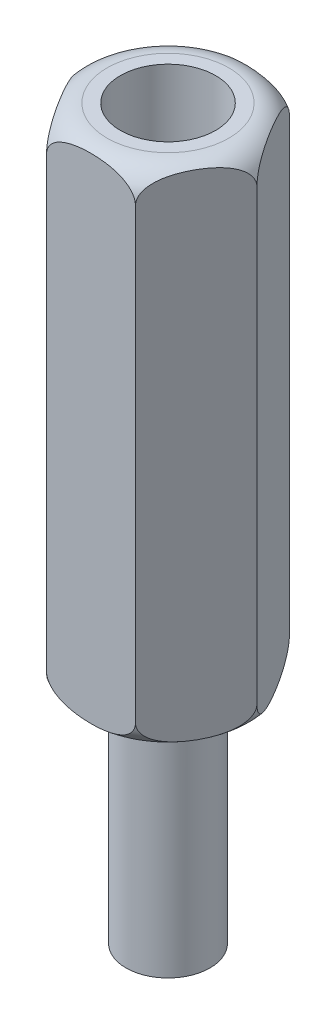
from build123d import *

# Parameters (mm, degrees)
BOSS_EXTRUDE1_DEPTH      = 18
M3_CLEARANCE_HOLE1_D     = 3.4
M3_CLEARANCE_HOLE1_DEPTH = 12
M3_CLEARANCE_HOLE1_TIP   = 1.021463052
SKETCH5_R                = 1.5
BOSS_EXTRUDE2_DEPTH      = 8


with BuildPart() as part:
    # Sketch1 → Boss-Extrude1 (new body)
    with BuildSketch(Plane(origin=(0, 0, 0), x_dir=(1, 0, 0), z_dir=(0, 1, 0))):
        Polygon((3.175426481, 0), (1.58771324, 2.75), (-1.58771324, 2.75), (-3.175426481, 0), (-1.58771324, -2.75), (1.58771324, -2.75), align=None)
    extrude(amount=BOSS_EXTRUDE1_DEPTH)

    # M3 Clearance Hole1
    with Locations(Plane(origin=(0, 18, 0), x_dir=(-1, 0, 0), z_dir=(0, 1, 0))):
        with Locations((0, 0)):
            Hole(M3_CLEARANCE_HOLE1_D / 2, depth=M3_CLEARANCE_HOLE1_DEPTH)
            with Locations((0, 0, -(M3_CLEARANCE_HOLE1_DEPTH + M3_CLEARANCE_HOLE1_TIP / 2))):  # 118° drill point
                Cone(0, M3_CLEARANCE_HOLE1_D / 2, M3_CLEARANCE_HOLE1_TIP, mode=Mode.SUBTRACT)

    # Sketch4 → Cut-Revolve1 (revolve, cut)
    with BuildSketch(Plane.XY):
        with BuildLine():
            Line((-2.175426481, 18), (-3.175426481, 18))
            Line((-3.175426481, 18), (-3.175426481, 17))
            ThreePointArc((-3.175426481, 17), (-2.882533262, 17.707106781), (-2.175426481, 18))
        make_face()
        with BuildLine():
            Line((-3.175426481, 1), (-3.175426481, 0))
            Line((-3.175426481, 0), (-2.175426481, 0))
            ThreePointArc((-2.175426481, 0), (-2.882533262, 0.292893219), (-3.175426481, 1))
        make_face()
    revolve(axis=Axis((0, 18, 0), (0, -1, 0)), mode=Mode.SUBTRACT)

    # Sketch5 → Boss-Extrude2 (add)
    with BuildSketch(Plane.XZ):
        Circle(SKETCH5_R)
    extrude(amount=BOSS_EXTRUDE2_DEPTH)


solid = part.part
